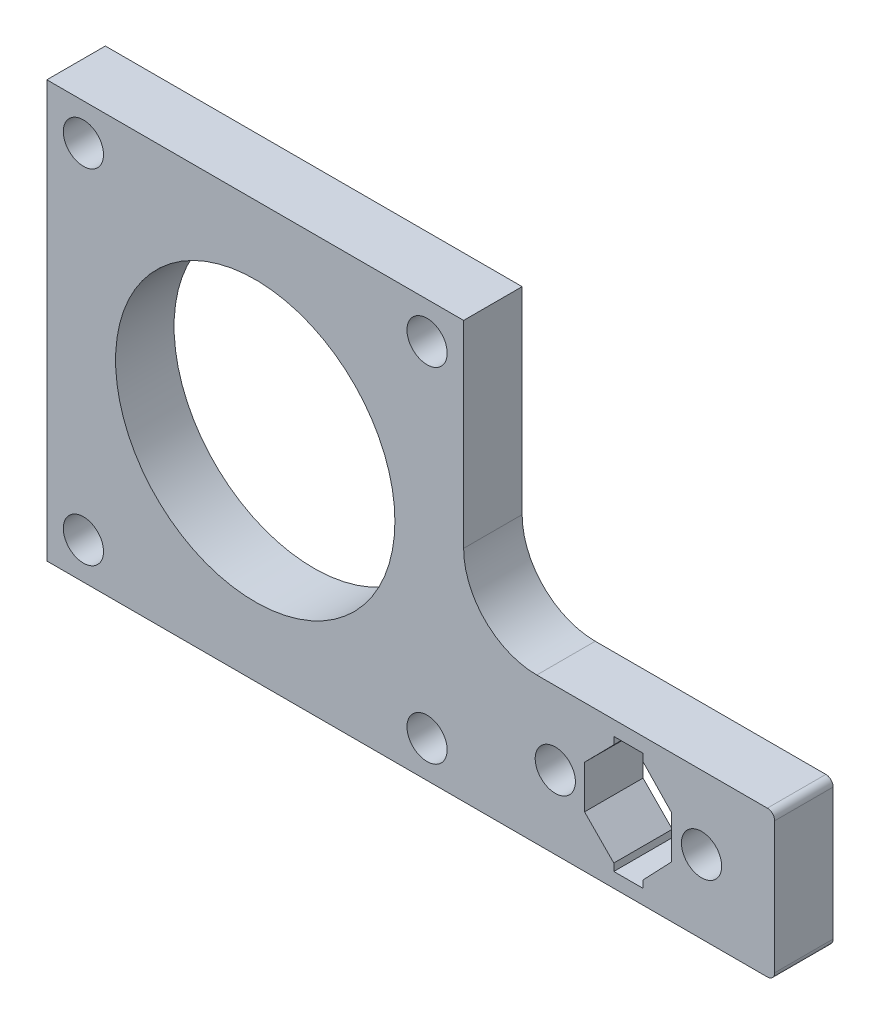
from build123d import *

# Parameters (mm, degrees)
STEPPER_PLATE_SKETCH_R   = 19.1
PLATE_BOSS_EXTRUDE_DEPTH = 8
FILLET1_R                = 10
FILLET2_R                = 1
M5_CLEARANCE_HOLE1_D     = 5.5


with BuildPart() as part:
    # Stepper Plate Sketch → Plate Boss-Extrude (new body)
    with BuildSketch(Plane.XY):
        Polygon((-22.536751464, 8), (-79.536751464, 8), (-79.536751464, -49), (20, -49), (20, -29), (-22.536751464, -29), align=None)
        with Locations((-51.036751464, -20.5)):
            Circle(STEPPER_PLATE_SKETCH_R, mode=Mode.SUBTRACT)
        Polygon((-2, -31), (2, -31), (2, -32), (5.88, -36.06), (5.88, -41.94), (2, -46), (2, -47), (-2, -47), (-2, -46), (-6, -41.94), (-6, -36.06), (-2, -32), align=None, mode=Mode.SUBTRACT)
    extrude(amount=-PLATE_BOSS_EXTRUDE_DEPTH)

    # Fillet1
    fillet1_edges = [part.edges().sort_by_distance(p)[0] for p in [
        (-22.536751464, -29, -4),
    ]]
    fillet(fillet1_edges, radius=FILLET1_R)

    # Fillet2
    fillet2_edges = [part.edges().sort_by_distance(p)[0] for p in [
        (20, -29, -4),
        (20, -49, -4),
    ]]
    fillet(fillet2_edges, radius=FILLET2_R)

    # M5 Clearance Hole1 (through all)
    with Locations(Plane.XY):
        with Locations((-74.536751464, 3), (-74.536751464, -44), (-27.536751464, -44), (-27.536751464, 3), (-10, -39), (10, -39)):
            Hole(M5_CLEARANCE_HOLE1_D / 2)


solid = part.part
